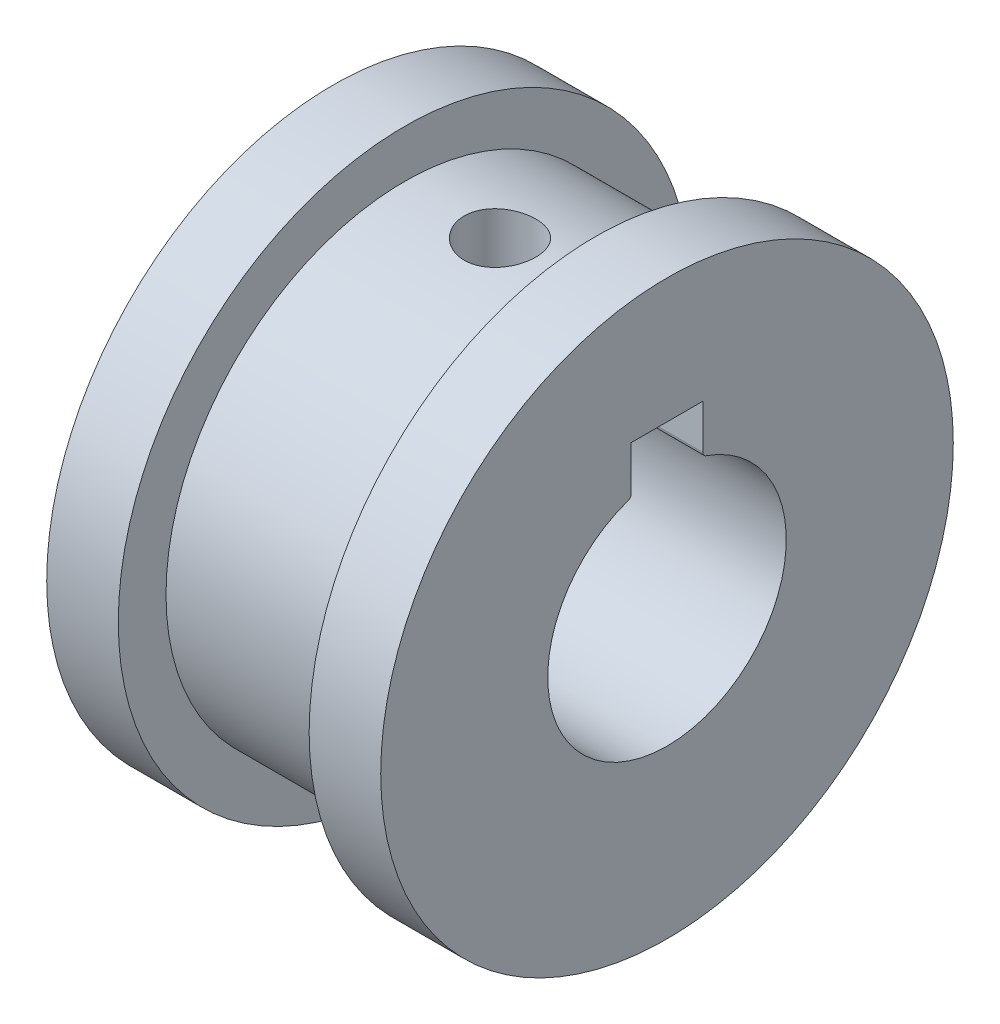
from build123d import *

# Parameters (mm, degrees)
SKETCH1_R               = 10
BOSS_EXTRUDE1_DEPTH     = 8
SKETCH3_R               = 12
BOSS_EXTRUDE2_DEPTH     = 3
SKETCH4_R               = 12
BOSS_EXTRUDE3_DEPTH     = 3
CUT_EXTRUDE2_DEPTH      = 3
CUT_EXTRUDE2_DEPTH_BACK = 11
SKETCH6_R               = 1.5
CUT_EXTRUDE3_DEPTH      = 5


with BuildPart() as part:
    # Sketch1 → Boss-Extrude1 (new body)
    with BuildSketch(Plane(origin=(0, 0, 0), x_dir=(0, 0, -1), z_dir=(1, 0, 0))):
        Circle(SKETCH1_R)
    extrude(amount=BOSS_EXTRUDE1_DEPTH)

    # Sketch3 → Boss-Extrude2 (add)
    with BuildSketch(Plane(origin=(8, 0, 0), x_dir=(0, 0, -1), z_dir=(1, 0, 0))):
        Circle(SKETCH3_R)
    extrude(amount=BOSS_EXTRUDE2_DEPTH)

    # Sketch4 → Boss-Extrude3 (add)
    with BuildSketch(Plane.ZY):
        Circle(SKETCH4_R)
    extrude(amount=BOSS_EXTRUDE3_DEPTH)

    # Sketch2 → Cut-Extrude2 (cut, two sides)
    with BuildSketch(Plane(origin=(8, 0, 0), x_dir=(0, 0, -1), z_dir=(1, 0, 0))) as cut_extrude2_sk:
        with BuildLine():
            Line((-1.5, 6.769696007), (1.5, 6.769696007))
            Line((1.5, 6.769696007), (1.5, 4.91426495))
            ThreePointArc((1.5, 4.91426495), (1.537093703, 4.79824108), (1.634615385, 4.72525476))
            ThreePointArc((1.634615385, 4.72525476), (0, -5), (-1.634615385, 4.72525476))
            ThreePointArc((-1.634615385, 4.72525476), (-1.537093703, 4.79824108), (-1.5, 4.91426495))
            Line((-1.5, 4.91426495), (-1.5, 6.769696007))
        make_face()
    extrude(amount=CUT_EXTRUDE2_DEPTH, mode=Mode.SUBTRACT)
    extrude(cut_extrude2_sk.sketch, amount=-CUT_EXTRUDE2_DEPTH_BACK, mode=Mode.SUBTRACT)

    # Sketch6 → Cut-Extrude3 (cut)
    with BuildSketch(Plane.XZ.offset(-6.769696007)):
        with Locations((4, 0)):
            Circle(SKETCH6_R)
    extrude(amount=-CUT_EXTRUDE3_DEPTH, mode=Mode.SUBTRACT)


solid = part.part
